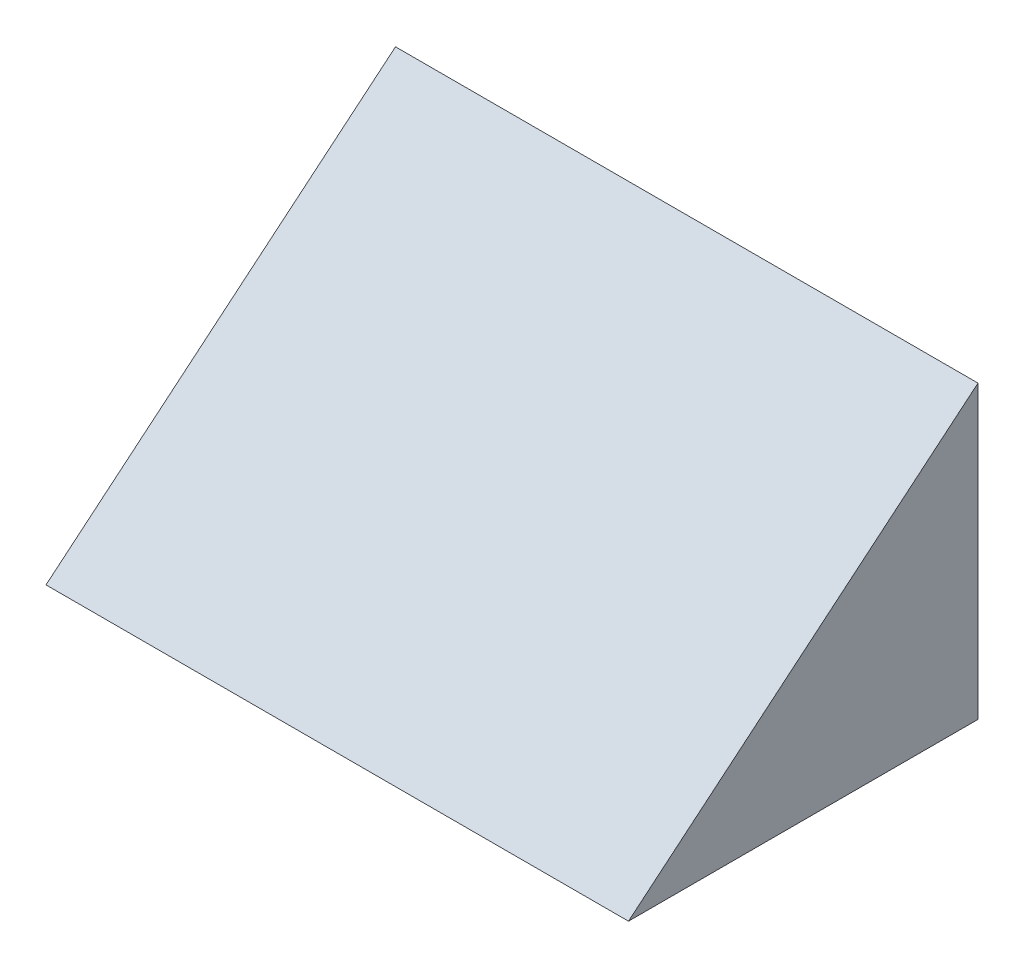
from build123d import *

# Parameters (mm, degrees)
BOSS_EXTRUDE1_DEPTH = 200


with BuildPart() as part:
    # Sketch1 → Boss-Extrude1 (new body)
    with BuildSketch(Plane(origin=(0, 0, 0), x_dir=(0, 0, -1), z_dir=(1, 0, 0))):
        Polygon((0, 0), (0, 100), (-120, 0), align=None)
    extrude(amount=BOSS_EXTRUDE1_DEPTH)


solid = part.part
